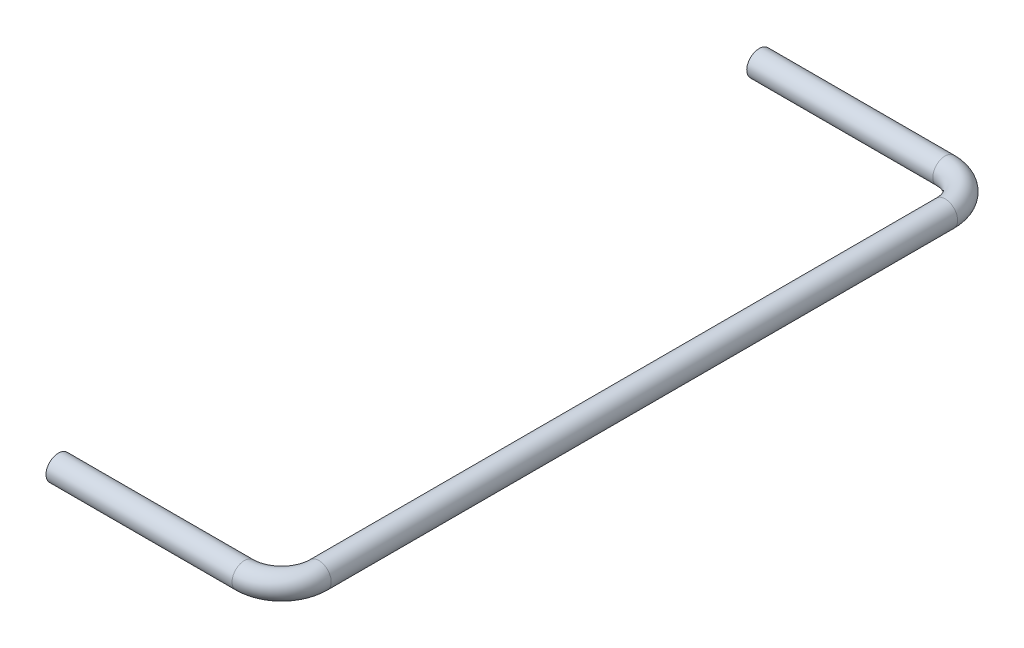
from build123d import *

# Parameters (mm, degrees)
SKETCH_1_R = 1


with BuildPart() as part:
    # По траектории1: sweep along a curve in space
    with BuildLine() as sweep_1_path:
        Line((0, 0, 0), (15, 0, 0))
        ThreePointArc((15, 0, 0), (17.121320344, 0, -0.878679656), (18, 0, -3))
        Line((18, 0, -3), (18, 0, -53.5))
        ThreePointArc((18, 0, -53.5), (17.121320344, 0, -55.621320344), (15, 0, -56.5))
        Line((15, 0, -56.5), (0, 0, -56.5))
    # Эскиз1 → По траектории1 (sweep)
    with BuildSketch(Plane(origin=(0, 0, 0), x_dir=(0, 0, -1), z_dir=(1, 0, 0))):
        Circle(SKETCH_1_R)
    sweep(path=sweep_1_path.line)


solid = part.part
